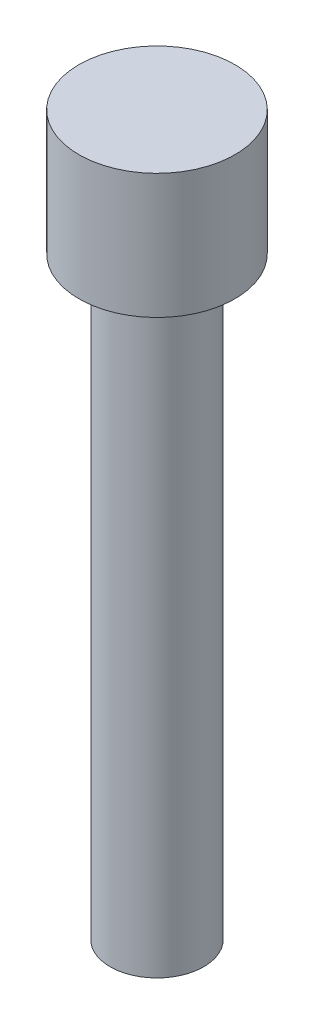
from build123d import *

# Parameters (mm, degrees)
SKETCH1_R                = 1.5
BOSS_EXTRUDE1_DEPTH      = 12.032999
BOSS_EXTRUDE1_DEPTH_BACK = 7
SKETCH2_R                = 2.5
BOSS_EXTRUDE2_DEPTH      = 4


with BuildPart() as part:
    # Sketch1 → Boss-Extrude1 (new body, two sides)
    with BuildSketch(Plane(origin=(0, 238.593099078, 0), x_dir=(1, 0, 0), z_dir=(0, 1, 0))) as boss_extrude1_sk:
        with Locations((-59.399538792, -183.810017212)):
            Circle(SKETCH1_R)
    extrude(amount=BOSS_EXTRUDE1_DEPTH)
    extrude(boss_extrude1_sk.sketch, amount=-BOSS_EXTRUDE1_DEPTH_BACK)

    # Sketch2 → Boss-Extrude2 (add)
    with BuildSketch(Plane(origin=(0, 250.626098268, 0), x_dir=(1, 0, 0), z_dir=(0, 1, 0))):
        with Locations((-59.399538792, -183.810017212)):
            Circle(SKETCH2_R)
    extrude(amount=BOSS_EXTRUDE2_DEPTH)


solid = part.part
